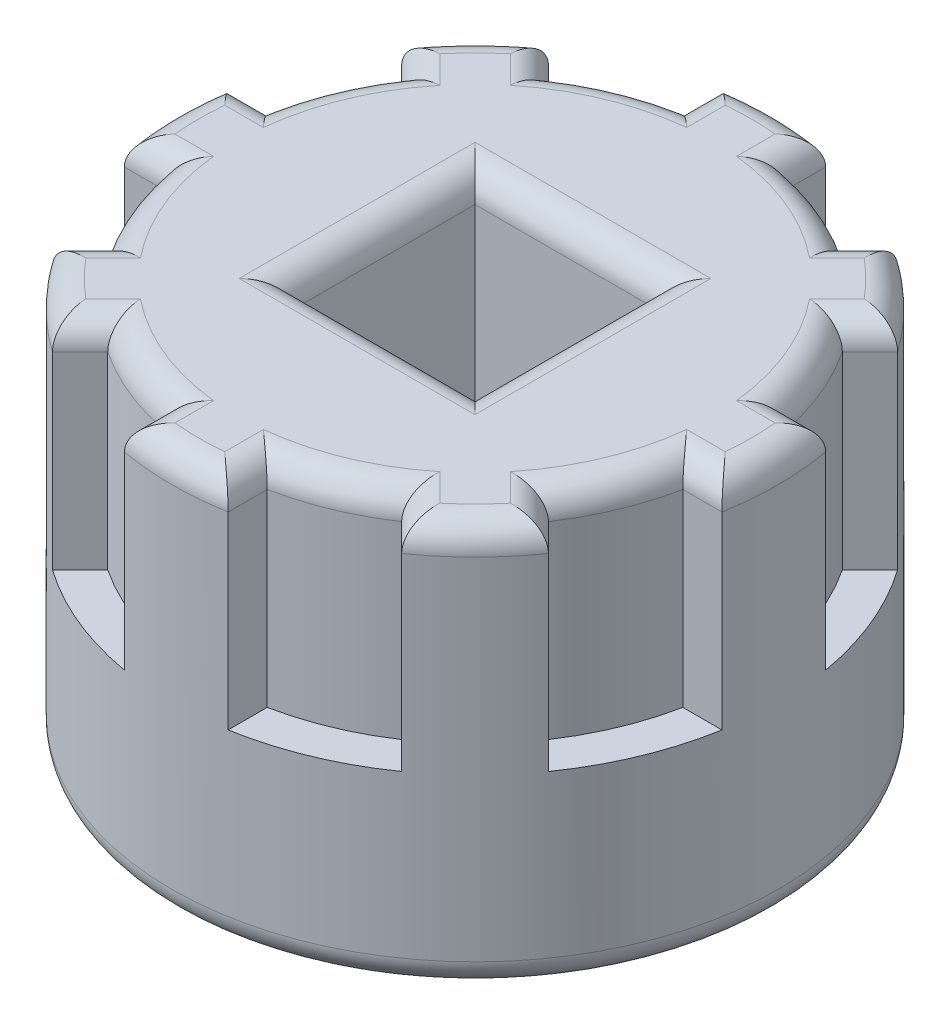
from build123d import *

# Parameters (mm, degrees)
SKETCH1_R               = 5.715
BOSS_EXTRUDE2_DEPTH     = 3.556
SKETCH2_R               = 4.990855354
BOSS_EXTRUDE3_DEPTH     = 4.064
SKETCH3_W               = 3.429
SKETCH3_H               = 3.429
CUT_EXTRUDE1_DEPTH      = 1
CUT_EXTRUDE1_DEPTH_BACK = 8.62
FILLET1_R               = 0.508


with BuildPart() as part:
    # Sketch1 → Boss-Extrude2 (new body)
    with BuildSketch(Plane(origin=(0, 0, 0), x_dir=(1, 0, 0), z_dir=(0, 1, 0))):
        Circle(SKETCH1_R)
    extrude(amount=BOSS_EXTRUDE2_DEPTH)

    # Sketch2 → Boss-Extrude3 (add)
    with BuildSketch(Plane(origin=(0, 3.556, 0), x_dir=(1, 0, 0), z_dir=(0, 1, 0))):
        Circle(SKETCH2_R)
        with BuildLine():
            ThreePointArc((0.9779, 5.630713684), (0, 5.715), (-0.9779, 5.630713684))
            Line((-0.9779, 5.630713684), (-0.9779, 4.894113684))
            ThreePointArc((-0.9779, 4.894113684), (0, 4.990855354), (0.9779, 4.894113684))
            Line((0.9779, 4.894113684), (0.9779, 5.630713684))
        make_face()
        with BuildLine():
            Line((-2.769181252, 4.152140695), (-3.290036107, 4.67299555))
            ThreePointArc((-3.290036107, 4.67299555), (-4.041115254, 4.041115254), (-4.67299555, 3.290036107))
            Line((-4.67299555, 3.290036107), (-4.152140695, 2.769181252))
            ThreePointArc((-4.152140695, 2.769181252), (-3.529067664, 3.529067664), (-2.769181252, 4.152140695))
        make_face()
        with BuildLine():
            Line((-4.894113684, 0.9779), (-5.630713684, 0.9779))
            ThreePointArc((-5.630713684, 0.9779), (-5.715, 0), (-5.630713684, -0.9779))
            Line((-5.630713684, -0.9779), (-4.894113684, -0.9779))
            ThreePointArc((-4.894113684, -0.9779), (-4.990855354, 0), (-4.894113684, 0.9779))
        make_face()
        with BuildLine():
            Line((-4.152140695, -2.769181252), (-4.67299555, -3.290036107))
            ThreePointArc((-4.67299555, -3.290036107), (-4.041115254, -4.041115254), (-3.290036107, -4.67299555))
            Line((-3.290036107, -4.67299555), (-2.769181252, -4.152140695))
            ThreePointArc((-2.769181252, -4.152140695), (-3.529067664, -3.529067664), (-4.152140695, -2.769181252))
        make_face()
        with BuildLine():
            Line((-0.9779, -4.894113684), (-0.9779, -5.630713684))
            ThreePointArc((-0.9779, -5.630713684), (0, -5.715), (0.9779, -5.630713684))
            Line((0.9779, -5.630713684), (0.9779, -4.894113684))
            ThreePointArc((0.9779, -4.894113684), (0, -4.990855354), (-0.9779, -4.894113684))
        make_face()
        with BuildLine():
            ThreePointArc((3.290036107, -4.67299555), (4.041115254, -4.041115254), (4.67299555, -3.290036107))
            Line((4.67299555, -3.290036107), (4.152140695, -2.769181252))
            ThreePointArc((4.152140695, -2.769181252), (3.529067664, -3.529067664), (2.769181252, -4.152140695))
            Line((2.769181252, -4.152140695), (3.290036107, -4.67299555))
        make_face()
        with BuildLine():
            ThreePointArc((5.715, 0), (5.693889431, 0.490762823), (5.630713684, 0.9779))
            Line((5.630713684, 0.9779), (4.894113684, 0.9779))
            ThreePointArc((4.894113684, 0.9779), (4.96661105, 0.491336789), (4.990855354, 0))
            ThreePointArc((4.990855354, 0), (4.96661105, -0.491336789), (4.894113684, -0.9779))
            Line((4.894113684, -0.9779), (5.630713684, -0.9779))
            ThreePointArc((5.630713684, -0.9779), (5.693889431, -0.490762823), (5.715, 0))
        make_face()
        with BuildLine():
            ThreePointArc((4.67299555, 3.290036107), (4.041115254, 4.041115254), (3.290036107, 4.67299555))
            Line((3.290036107, 4.67299555), (2.769181252, 4.152140695))
            ThreePointArc((2.769181252, 4.152140695), (3.529067664, 3.529067664), (4.152140695, 2.769181252))
            Line((4.152140695, 2.769181252), (4.67299555, 3.290036107))
        make_face()
    extrude(amount=BOSS_EXTRUDE3_DEPTH)

    # Sketch3 → Cut-Extrude1 (cut, two sides)
    with BuildSketch(Plane(origin=(0, 7.62, 0), x_dir=(1, 0, 0), z_dir=(0, 1, 0))) as cut_extrude1_sk:
        Rectangle(SKETCH3_W, SKETCH3_H)
    extrude(amount=CUT_EXTRUDE1_DEPTH, mode=Mode.SUBTRACT)
    extrude(cut_extrude1_sk.sketch, amount=-CUT_EXTRUDE1_DEPTH_BACK, mode=Mode.SUBTRACT)

    # Fillet1
    fillet1_edges = [part.edges().sort_by_distance(p)[0] for p in [
        (0, 7.62, -1.7145),
        (-1.7145, 7.62, 0),
        (0, 7.62, 1.7145),
        (1.7145, 7.62, 0),
        (1.7145, 0, 0),
        (0, 0, 1.7145),
        (-1.7145, 0, 0),
        (0, 0, -1.7145),
        (-5.715, 0, 0),
        (-0.9779, 7.62, 5.262413684),
        (0.9779, 7.62, 5.262413684),
        (1.909917657, 7.62, 4.610949111),
        (4.041115254, 7.62, 4.041115254),
        (4.412568123, 7.62, 3.02960868),
        (4.610949111, 7.62, 1.909917657),
        (5.715, 7.62, 0),
        (5.262413684, 7.62, -0.9779),
        (4.610949111, 7.62, -1.909917657),
        (4.041115254, 7.62, -4.041115254),
        (3.02960868, 7.62, -4.412568123),
        (1.909917657, 7.62, -4.610949111),
        (0, 7.62, -5.715),
        (-0.9779, 7.62, -5.262413684),
        (-1.909917657, 7.62, -4.610949111),
        (-4.041115254, 7.62, -4.041115254),
        (-4.412568123, 7.62, -3.02960868),
        (-4.610949111, 7.62, -1.909917657),
        (-5.715, 7.62, 0),
        (-5.262413684, 7.62, 0.9779),
        (-4.610949111, 7.62, 1.909917657),
        (-4.041115254, 7.62, 4.041115254),
        (-3.02960868, 7.62, 4.412568123),
        (-1.909917657, 7.62, 4.610949111),
        (0, 7.62, 5.715),
        (3.02960868, 7.62, 4.412568123),
        (5.262413684, 7.62, 0.9779),
        (4.412568123, 7.62, -3.02960868),
        (0.9779, 7.62, -5.262413684),
        (-3.02960868, 7.62, -4.412568123),
        (-5.262413684, 7.62, -0.9779),
        (-4.412568123, 7.62, 3.02960868),
    ]]
    fillet(fillet1_edges, radius=FILLET1_R)


solid = part.part
